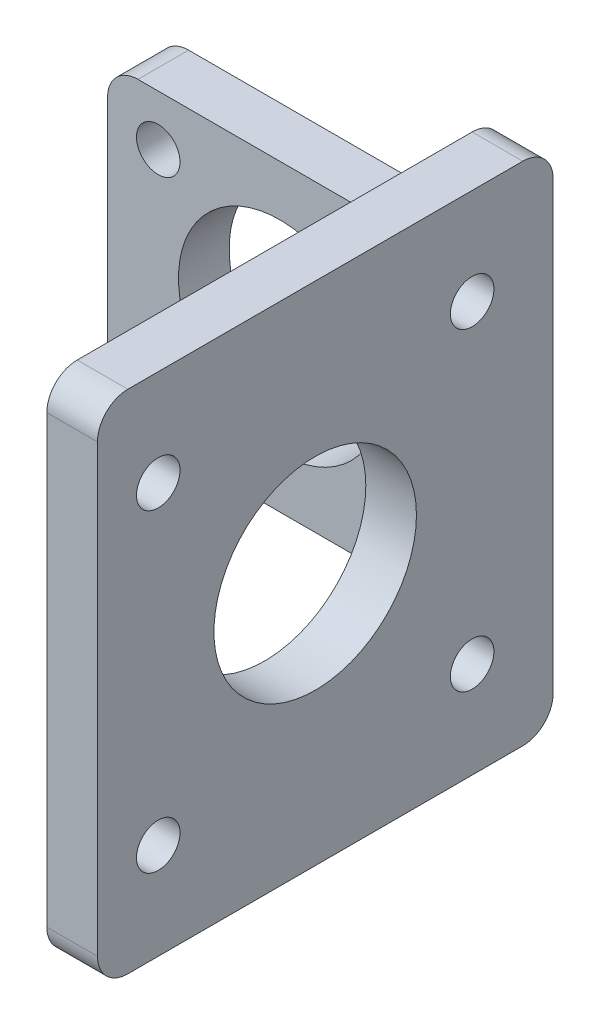
from build123d import *

# Parameters (mm, degrees)
SKETCH2_W           = 34
SKETCH2_H           = 30
SKETCH2_R           = 10
SKETCH2_R_2         = 2.15
BOSS_EXTRUDE1_DEPTH = 5
SKETCH6_W           = 5
SKETCH6_H           = 50
BOSS_EXTRUDE3_DEPTH = 40
SKETCH10_W          = 5
SKETCH10_H          = 30
BOSS_EXTRUDE4_DEPTH = 5
SKETCH11_W          = 5
SKETCH11_H          = 10
BOSS_EXTRUDE5_DEPTH = 5
FILLET3_R           = 3
FILLET4_R           = 3
FILLET5_R           = 3
SKETCH12_R          = 2.15
SKETCH12_R_2        = 10
CUT_EXTRUDE3_DEPTH  = 5


with BuildPart() as part:
    # Sketch2 → Boss-Extrude1 (new body)
    with BuildSketch(Plane.XY):
        with Locations((17, -15)):
            Rectangle(SKETCH2_W, SKETCH2_H)
        with Locations((17, -15)):
            Circle(SKETCH2_R, mode=Mode.SUBTRACT)
        with Locations((29, -5)):
            Circle(SKETCH2_R_2, mode=Mode.SUBTRACT)
        with Locations((5, -5)):
            Circle(SKETCH2_R_2, mode=Mode.SUBTRACT)
        with Locations((5, -25)):
            Circle(SKETCH2_R_2, mode=Mode.SUBTRACT)
        with Locations((29, -25)):
            Circle(SKETCH2_R_2, mode=Mode.SUBTRACT)
    extrude(amount=BOSS_EXTRUDE1_DEPTH)



with BuildPart() as body_2:
    # Sketch6 → Boss-Extrude3 (new body)
    with BuildSketch(Plane.XY.offset(5)):
        with Locations((36.5, -15)):
            Rectangle(SKETCH6_W, SKETCH6_H)
    extrude(amount=BOSS_EXTRUDE3_DEPTH)


with BuildPart() as part_1:
    add(part.part)

    add(body_2.part)  # Boss-Extrude4 merges body 2
    # Sketch10 → Boss-Extrude4 (add)
    with BuildSketch(Plane(origin=(34, 0, 0), x_dir=(0, 0, -1), z_dir=(1, 0, 0))):
        with Locations((-2.5, -15)):
            Rectangle(SKETCH10_W, SKETCH10_H)
    extrude(amount=BOSS_EXTRUDE4_DEPTH)

    # Sketch11 → Boss-Extrude5 (add)
    with BuildSketch(Plane(origin=(0, 0, 5), x_dir=(-1, 0, 0), z_dir=(0, 0, -1))):
        with Locations((-36.5, -35)):
            Rectangle(SKETCH11_W, SKETCH11_H)
        with Locations((-36.5, 5)):
            Rectangle(SKETCH11_W, SKETCH11_H)
    extrude(amount=BOSS_EXTRUDE5_DEPTH)

    # Fillet3
    fillet3_edges = [part_1.edges().sort_by_distance(p)[0] for p in [
        (34, -30, 2.5),
        (34, 0, 2.5),
        (0, -30, 2.5),
        (0, 0, 2.5),
    ]]
    fillet(fillet3_edges, radius=FILLET3_R)

    # Fillet4
    fillet4_edges = [part_1.edges().sort_by_distance(p)[0] for p in [
        (36.5, -40, 0),
    ]]
    fillet(fillet4_edges, radius=FILLET4_R)

    # Fillet5
    fillet5_edges = [part_1.edges().sort_by_distance(p)[0] for p in [
        (36.5, -40, 45),
        (36.5, 10, 45),
        (36.5, 10, 0),
    ]]
    fillet(fillet5_edges, radius=FILLET5_R)

    # Sketch12 → Cut-Extrude3 (cut)
    with BuildSketch(Plane(origin=(39, 0, 0), x_dir=(0, 0, -1), z_dir=(1, 0, 0))):
        with Locations((-39, 0.5)):
            Circle(SKETCH12_R)
        with Locations((-23.5, -15)):
            Circle(SKETCH12_R_2)
        with Locations((-8, 0.5)):
            Circle(SKETCH12_R)
        with Locations((-8, -30.5)):
            Circle(SKETCH12_R)
        with Locations((-39, -30.5)):
            Circle(SKETCH12_R)
    extrude(amount=-CUT_EXTRUDE3_DEPTH, mode=Mode.SUBTRACT)


solid = part_1.part
